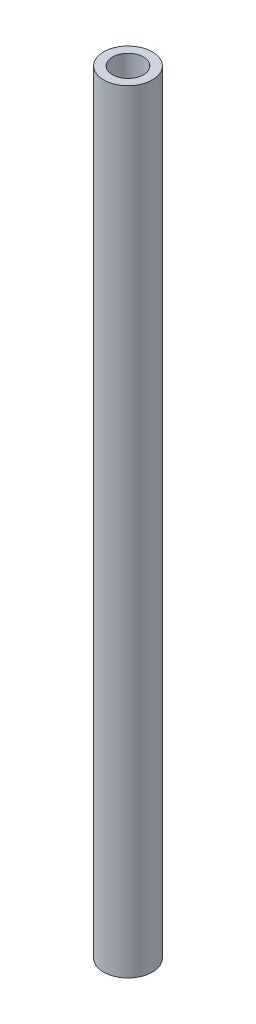
from build123d import *

# Parameters (mm, degrees)
SKETCH_1_R      = 3.15
SKETCH_1_R_2    = 2
EXTRUDE_1_DEPTH = 100


with BuildPart() as part:
    # 草图1 → 凸台-拉伸1 (new body)
    with BuildSketch(Plane(origin=(0, 0, 0), x_dir=(1, 0, 0), z_dir=(0, 1, 0))):
        Circle(SKETCH_1_R)
        Circle(SKETCH_1_R_2, mode=Mode.SUBTRACT)
    extrude(amount=EXTRUDE_1_DEPTH)


solid = part.part
